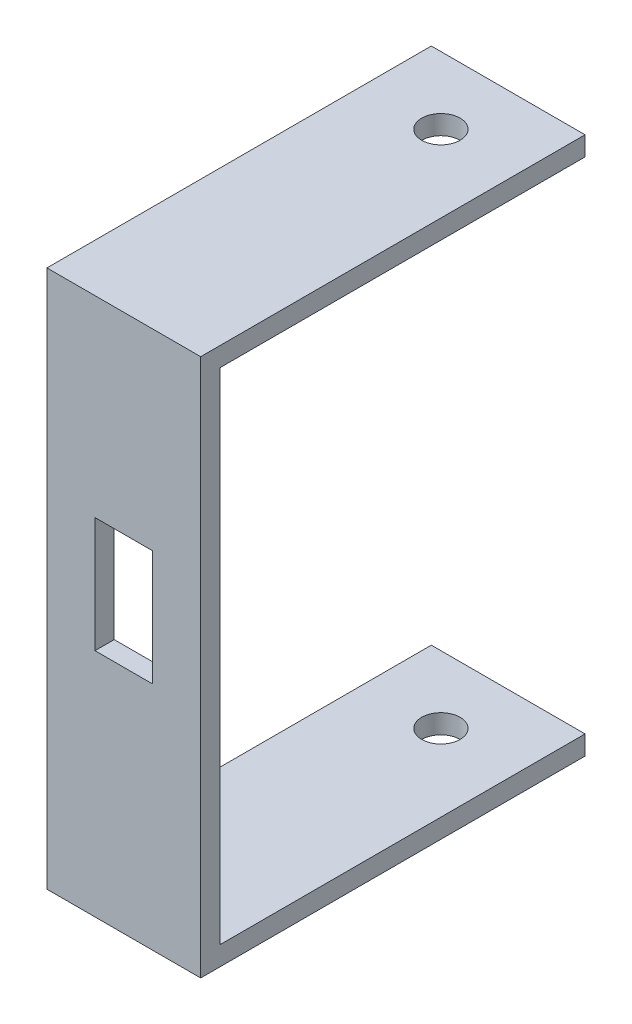
from build123d import *

# Parameters (mm, degrees)
SKETCH1_W           = 25.4
SKETCH1_H           = 82.55
BOSS_EXTRUDE1_DEPTH = 3.175
SKETCH2_W           = 25.4
SKETCH2_H           = 3.175
SKETCH2_H_2         = 60.325
BOSS_EXTRUDE2_DEPTH = 3.175
SKETCH5_W           = 9.525
SKETCH5_H           = 19.05
CUT_EXTRUDE2_DEPTH  = 64.5
SKETCH6_R           = 3.175
CUT_EXTRUDE3_DEPTH  = 89.9


with BuildPart() as part:
    # Sketch1 → Boss-Extrude1 (new body)
    with BuildSketch(Plane.XY):
        Rectangle(SKETCH1_W, SKETCH1_H)
    extrude(amount=BOSS_EXTRUDE1_DEPTH)

    # Sketch2 → Boss-Extrude2 (add)
    with BuildSketch(Plane(origin=(0, 41.275, 0), x_dir=(1, 0, 0), z_dir=(0, 1, 0))):
        with Locations((0, -1.5875)):
            Rectangle(SKETCH2_W, SKETCH2_H)
        with Locations((0, 30.1625)):
            Rectangle(SKETCH2_W, SKETCH2_H_2)
    boss_extrude2 = extrude(amount=BOSS_EXTRUDE2_DEPTH)

    # Sketch5 → Cut-Extrude2 (cut, through all)
    with BuildSketch(Plane.XY.offset(3.175)):
        with Locations((0, 3.175)):
            Rectangle(SKETCH5_W, SKETCH5_H)
    extrude(amount=-CUT_EXTRUDE2_DEPTH, mode=Mode.SUBTRACT)

    # Mirror1: Boss-Extrude2 across plane
    add(boss_extrude2.mirror(Plane.ZX))

    # Sketch6 → Cut-Extrude3 (cut, through all)
    with BuildSketch(Plane(origin=(0, 44.45, 0), x_dir=(1, 0, 0), z_dir=(0, 1, 0))):
        with Locations((0, 49.2125)):
            Circle(SKETCH6_R)
    extrude(amount=-CUT_EXTRUDE3_DEPTH, mode=Mode.SUBTRACT)


solid = part.part
